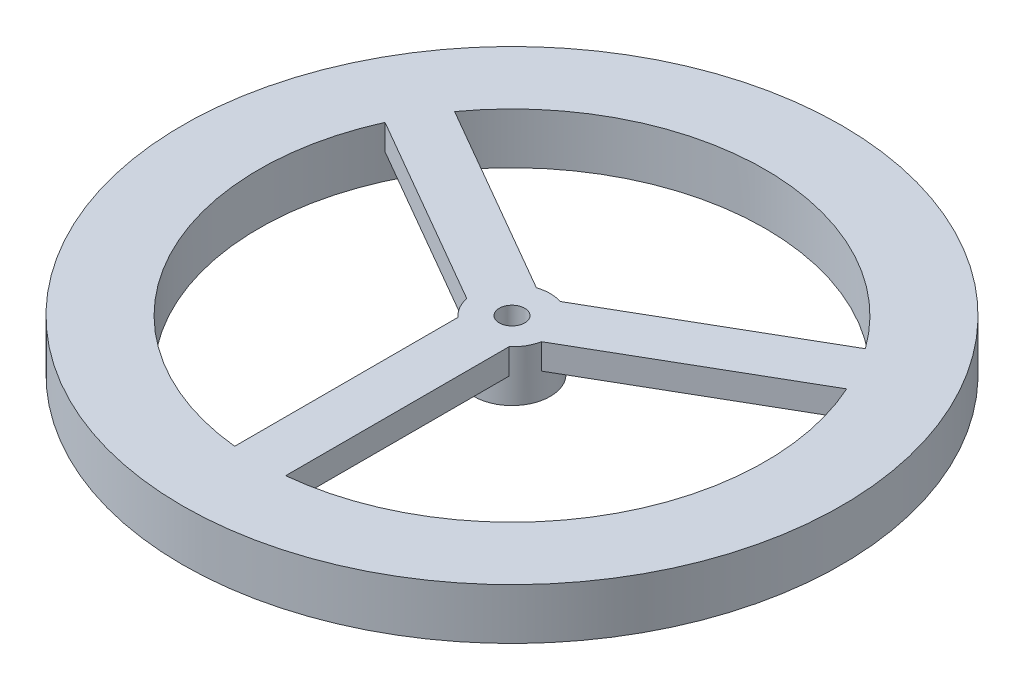
from build123d import *

# Parameters (mm, degrees)
SKETCH1_R             = 64.67
SKETCH1_R_2           = 49.67
BOSS_EXTRUDE1_DEPTH   = 10
SKETCH1_R_3           = 7.5
SKETCH1_R_4           = 2.5
BOSS_EXTRUDE1_2_DEPTH = 10
SKETCH2_W             = 10
SKETCH2_H             = 44.079830056
BOSS_EXTRUDE2_DEPTH   = 5
CIRPATTERN1_COUNT     = 3


with BuildPart() as part:
    # Sketch1 → Boss-Extrude1 (new body)
    with BuildSketch(Plane(origin=(0, 0, 0), x_dir=(1, 0, 0), z_dir=(0, 1, 0))):
        Circle(SKETCH1_R)
        Circle(SKETCH1_R_2, mode=Mode.SUBTRACT)
    extrude(amount=-BOSS_EXTRUDE1_DEPTH)



with BuildPart() as body_2:
    # Sketch1 → Boss-Extrude1 2 (new body)
    with BuildSketch(Plane(origin=(0, 0, 0), x_dir=(1, 0, 0), z_dir=(0, 1, 0))):
        Circle(SKETCH1_R_3)
        Circle(SKETCH1_R_4, mode=Mode.SUBTRACT)
    extrude(amount=-BOSS_EXTRUDE1_2_DEPTH)


with BuildPart() as part_1:
    add(part.part)

    add(body_2.part)  # Boss-Extrude2 merges body 2
    # Sketch2 → Boss-Extrude2 (add)
    with BuildSketch(Plane(origin=(0, 0, 0), x_dir=(1, 0, 0), z_dir=(0, 1, 0))):
        with Locations((0, -27.630084972)):
            Rectangle(SKETCH2_W, SKETCH2_H)
    boss_extrude2 = extrude(amount=-BOSS_EXTRUDE2_DEPTH)

    # CirPattern1: Boss-Extrude2 ×3 about axis
    cirpattern1_axis = Axis((0, 0, 0), (0, 1, 0))
    for i in range(1, CIRPATTERN1_COUNT):
        add(boss_extrude2.rotate(cirpattern1_axis, i * 360 / CIRPATTERN1_COUNT))


solid = part_1.part
